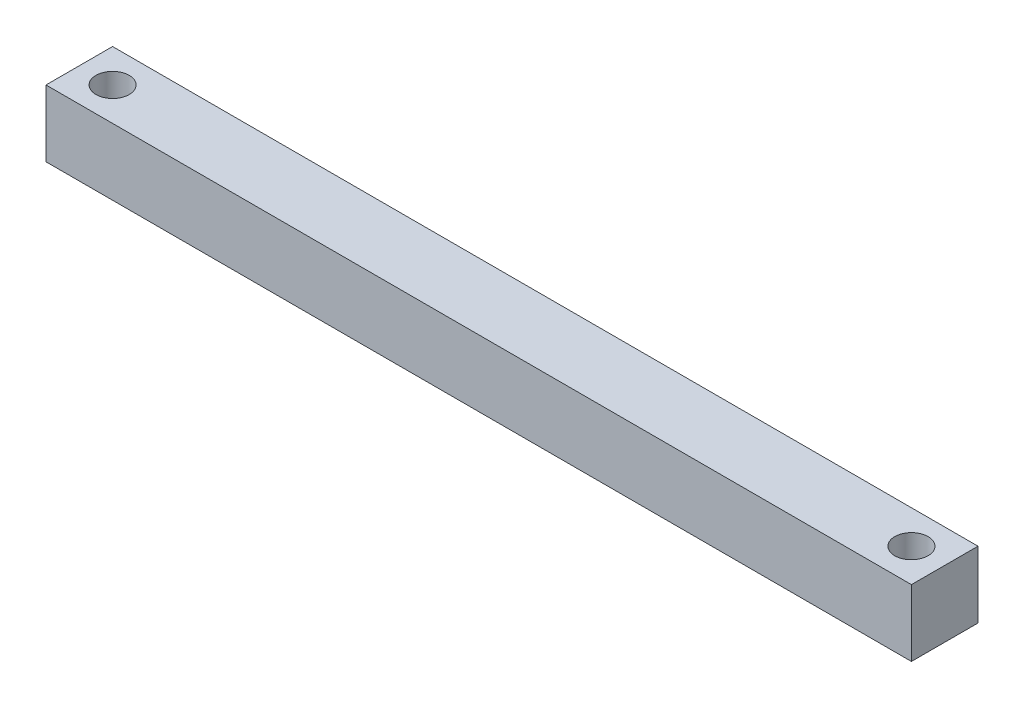
from build123d import *

# Parameters (mm, degrees)
SKETCH1_W           = 25.4
SKETCH1_H           = 25.4
BOSS_EXTRUDE1_DEPTH = 330.2
SKETCH2_R           = 6.35
CUT_EXTRUDE1_DEPTH  = 26.4


with BuildPart() as part:
    # Sketch1 → Boss-Extrude1 (new body)
    with BuildSketch(Plane(origin=(0, 0, 0), x_dir=(0, 0, -1), z_dir=(1, 0, 0))):
        with Locations((-12.7, 12.7)):
            Rectangle(SKETCH1_W, SKETCH1_H)
    extrude(amount=BOSS_EXTRUDE1_DEPTH)

    # Sketch2 → Cut-Extrude1 (cut, through all)
    with BuildSketch(Plane(origin=(0, 25.4, 0), x_dir=(1, 0, 0), z_dir=(0, 1, 0))):
        with Locations((317.5, -12.7)):
            Circle(SKETCH2_R)
        with Locations((12.7, -12.7)):
            Circle(SKETCH2_R)
    extrude(amount=-CUT_EXTRUDE1_DEPTH, mode=Mode.SUBTRACT)


solid = part.part
